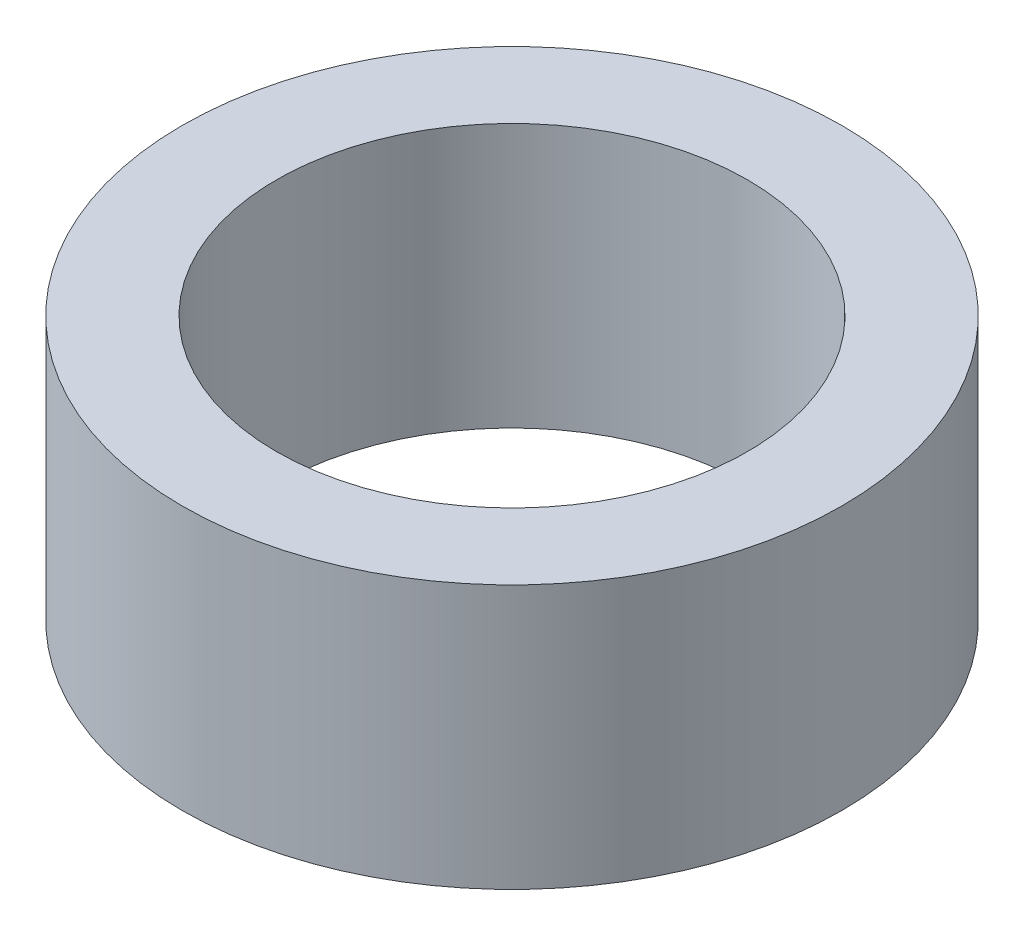
from build123d import *

# Parameters (mm, degrees)
SKETCH1_R           = 5.55625
SKETCH1_R_2         = 3.96875
BOSS_EXTRUDE1_DEPTH = 4.445


with BuildPart() as part:
    # Sketch1 → Boss-Extrude1 (new body)
    with BuildSketch(Plane(origin=(0, 0, 0), x_dir=(1, 0, 0), z_dir=(0, 1, 0))):
        Circle(SKETCH1_R)
        Circle(SKETCH1_R_2, mode=Mode.SUBTRACT)
    extrude(amount=-BOSS_EXTRUDE1_DEPTH)


solid = part.part
